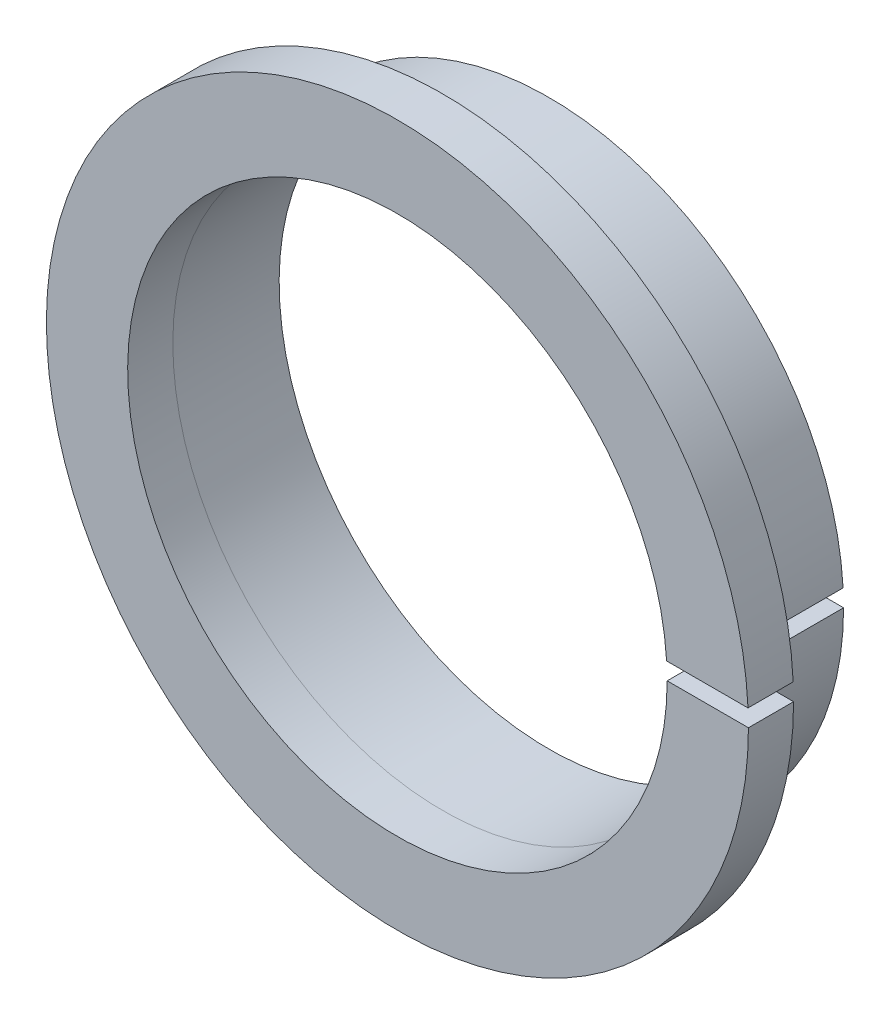
from build123d import *

# Parameters (mm, degrees)
BOSS_EXTRUDE2_DEPTH = 2
BOSS_EXTRUDE3_DEPTH = 4.71


with BuildPart() as part:
    # Sketch1 → Boss-Extrude2 (new body)
    with BuildSketch(Plane.XY):
        with BuildLine():
            Line((11.925891602, 0.750005761), (15.531174529, 0.750066382))
            ThreePointArc((15.531174529, 0.750066382), (-15.544767078, -0.375158498), (15.549275935, 3.0615e-05))
            Line((15.549275935, 3.0615e-05), (11.94945183, -2.9915e-05))
            ThreePointArc((11.94945183, -2.9915e-05), (-11.943555264, -0.375172617), (11.925891602, 0.750005761))
        make_face()
    extrude(amount=-BOSS_EXTRUDE2_DEPTH)


with BuildPart() as body_2:
    # Sketch2 → Boss-Extrude3 (new body)
    with BuildSketch(Plane(origin=(0, 0, -2), x_dir=(-1, 0, 0), z_dir=(0, 0, -1))):
        with BuildLine():
            Line((-11.949441301, -1.8109e-05), (-13.054393914, 1.8645e-05))
            ThreePointArc((-13.054393914, 1.8645e-05), (13.049018878, -0.375186095), (-13.032829211, 0.750041992))
            Line((-13.032829211, 0.750041992), (-11.925881078, 0.750005172))
            ThreePointArc((-11.925881078, 0.750005172), (11.943565601, -0.375179241), (-11.949441301, -1.8109e-05))
        make_face()
    extrude(amount=BOSS_EXTRUDE3_DEPTH)


solid = Compound([part.part, body_2.part])
